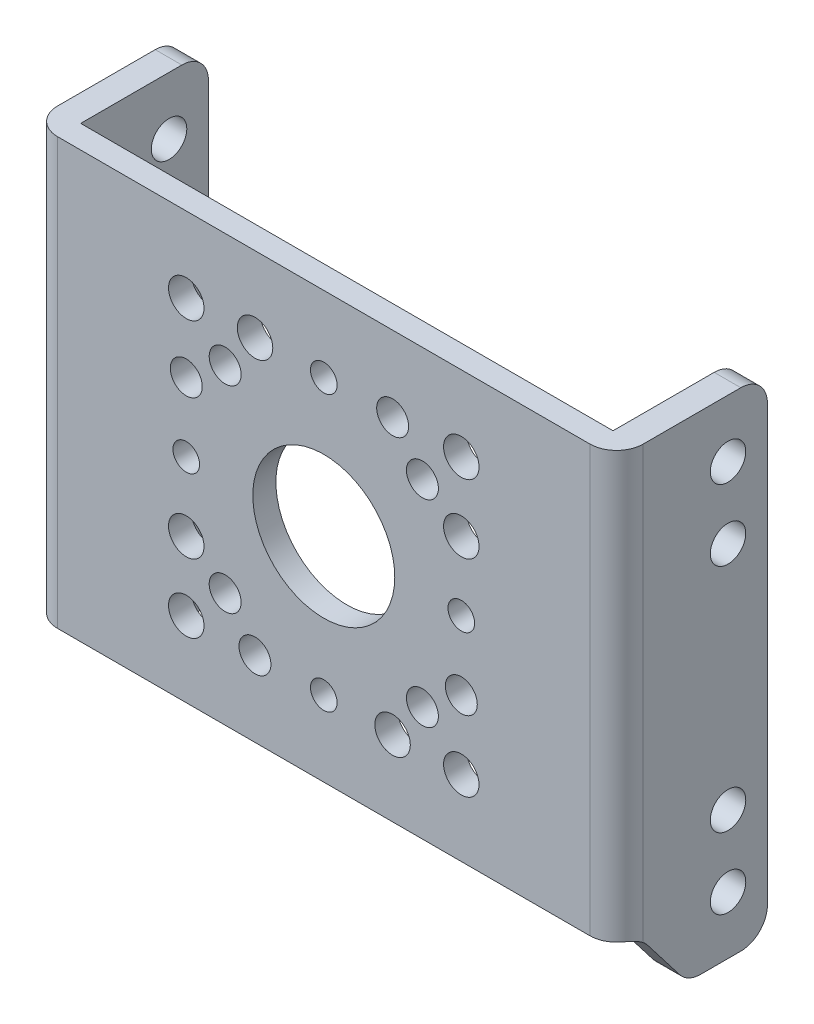
from build123d import *

# Parameters (mm, degrees)
SKETCH1_W           = 33
SKETCH1_H           = 24
SKETCH1_R           = 4
SKETCH1_R_2         = 1
SKETCH1_R_3         = 0.75
SKETCH1_R_4         = 0.9
BOSS_EXTRUDE1_DEPTH = 1.3
SKETCH2_R           = 1
BOSS_EXTRUDE2_DEPTH = 1.5
FILLET1_R           = 1.5


with BuildPart() as part:
    # Sketch1 → Boss-Extrude1 (new body)
    with BuildSketch(Plane.XY):
        Rectangle(SKETCH1_W, SKETCH1_H)
        Circle(SKETCH1_R, mode=Mode.SUBTRACT)
        with Locations((-7.75, 7.75)):
            Circle(SKETCH1_R_2, mode=Mode.SUBTRACT)
        with Locations((7.75, 7.75)):
            Circle(SKETCH1_R_2, mode=Mode.SUBTRACT)
        with Locations((7.75, -7.75)):
            Circle(SKETCH1_R_2, mode=Mode.SUBTRACT)
        with Locations((-7.75, -7.75)):
            Circle(SKETCH1_R_2, mode=Mode.SUBTRACT)
        with Locations((0, 7.75)):
            Circle(SKETCH1_R_3, mode=Mode.SUBTRACT)
        with Locations((-3.875, 7.75)):
            Circle(SKETCH1_R_2, mode=Mode.SUBTRACT)
        with Locations((3.88, 7.75)):
            Circle(SKETCH1_R_4, mode=Mode.SUBTRACT)
        with Locations((-5.557968978, 5.557968978)):
            Circle(SKETCH1_R_4, mode=Mode.SUBTRACT)
        with Locations((7.75, 3.875)):
            Circle(SKETCH1_R_2, mode=Mode.SUBTRACT)
        with Locations((7.75, 0)):
            Circle(SKETCH1_R_3, mode=Mode.SUBTRACT)
        with Locations((7.75, -3.88)):
            Circle(SKETCH1_R_4, mode=Mode.SUBTRACT)
        with Locations((5.557968978, 5.557968978)):
            Circle(SKETCH1_R_4, mode=Mode.SUBTRACT)
        with Locations((3.875, -7.75)):
            Circle(SKETCH1_R_2, mode=Mode.SUBTRACT)
        with Locations((0, -7.75)):
            Circle(SKETCH1_R_3, mode=Mode.SUBTRACT)
        with Locations((-3.88, -7.75)):
            Circle(SKETCH1_R_4, mode=Mode.SUBTRACT)
        with Locations((5.557968978, -5.557968978)):
            Circle(SKETCH1_R_4, mode=Mode.SUBTRACT)
        with Locations((-7.75, -3.875)):
            Circle(SKETCH1_R_2, mode=Mode.SUBTRACT)
        with Locations((-7.75, 0)):
            Circle(SKETCH1_R_3, mode=Mode.SUBTRACT)
        with Locations((-7.75, 3.88)):
            Circle(SKETCH1_R_4, mode=Mode.SUBTRACT)
        with Locations((-5.557968978, -5.557968978)):
            Circle(SKETCH1_R_4, mode=Mode.SUBTRACT)
    extrude(amount=BOSS_EXTRUDE1_DEPTH)

    # Sketch2 → Boss-Extrude2 (add)
    with BuildSketch(Plane(origin=(16.5, 0, 0), x_dir=(0, 0, -1), z_dir=(1, 0, 0))):
        with BuildLine():
            Line((5.7, 12), (0, 12))
            Line((0, 12), (0, -12))
            Line((0, -12), (-0.73731738, -12))
            ThreePointArc((-0.73731738, -12), (-0.075617967, -12.153837348), (0.450356003, -12.583794819))
            Line((0.450356003, -12.583794819), (2.249643997, -14.916205181))
            ThreePointArc((2.249643997, -14.916205181), (2.775617967, -15.346162652), (3.43731738, -15.5))
            Line((3.43731738, -15.5), (5.7, -15.5))
            ThreePointArc((5.7, -15.5), (6.760660172, -15.060660172), (7.2, -14))
            Line((7.2, -14), (7.2, 10.5))
            ThreePointArc((7.2, 10.5), (6.760660172, 11.560660172), (5.7, 12))
        make_face()
        with Locations((4.98, -12.25)):
            Circle(SKETCH2_R, mode=Mode.SUBTRACT)
        with Locations((4.98, -8.25)):
            Circle(SKETCH2_R, mode=Mode.SUBTRACT)
        with Locations((4.98, 4.75)):
            Circle(SKETCH2_R, mode=Mode.SUBTRACT)
        with Locations((4.98, 8.75)):
            Circle(SKETCH2_R, mode=Mode.SUBTRACT)
    boss_extrude2 = extrude(amount=-BOSS_EXTRUDE2_DEPTH)

    # Mirror1: Boss-Extrude2 across plane
    add(boss_extrude2.mirror(Plane(origin=(0, 0, 0), x_dir=(0, 0, 1), z_dir=(1, 0, 0))))

    # Fillet1
    fillet1_edges = [part.edges().sort_by_distance(p)[0] for p in [
        (-16.5, 0, 1.3),
        (16.5, 0, 1.3),
    ]]
    fillet(fillet1_edges, radius=FILLET1_R)


solid = part.part
